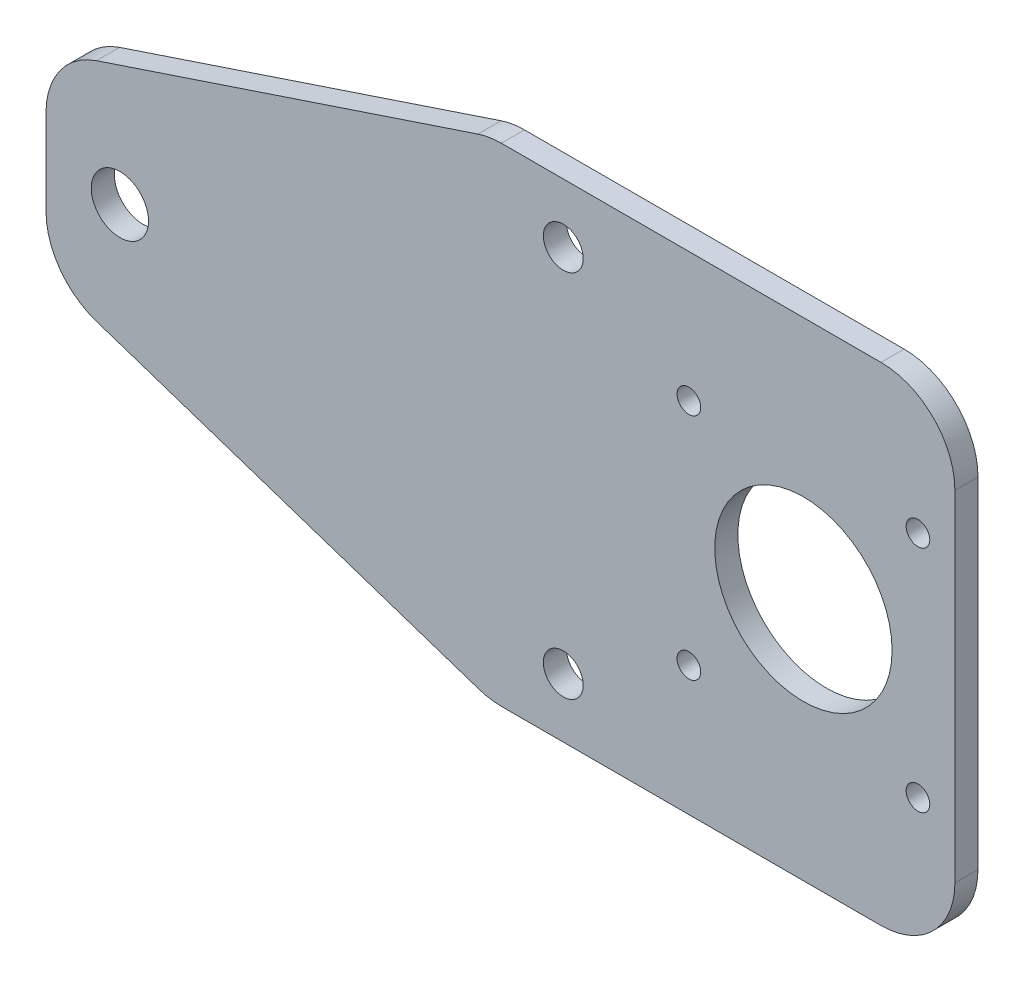
from build123d import *

# Parameters (mm, degrees)
MODEL_R             = 2.7
MODEL_R_2           = 3.875
MODEL_R_3           = 12
MODEL_R_4           = 1.6
BOSS_EXTRUDE1_DEPTH = 3.125
FILLET1_R           = 10


with BuildPart() as part:
    # Model → Boss-Extrude1 (new body)
    with BuildSketch(Plane.XY):
        Polygon((-0.063524835, 46), (-0.063524835, 20), (60, 0), (122.936475165, 0), (122.936475165, 66), (59.936475165, 66), align=None)
        with Locations((69.936475165, 8)):
            Circle(MODEL_R, mode=Mode.SUBTRACT)
        with Locations((9.936475165, 33)):
            Circle(MODEL_R_2, mode=Mode.SUBTRACT)
        with Locations((69.936475165, 58)):
            Circle(MODEL_R, mode=Mode.SUBTRACT)
        with Locations((102.436475165, 33)):
            Circle(MODEL_R_3, mode=Mode.SUBTRACT)
        with Locations((86.936475165, 48.5)):
            Circle(MODEL_R_4, mode=Mode.SUBTRACT)
        with Locations((117.936475165, 48.5)):
            Circle(MODEL_R_4, mode=Mode.SUBTRACT)
        with Locations((86.936475165, 17.5)):
            Circle(MODEL_R_4, mode=Mode.SUBTRACT)
        with Locations((117.936475165, 17.5)):
            Circle(MODEL_R_4, mode=Mode.SUBTRACT)
    extrude(amount=BOSS_EXTRUDE1_DEPTH)

    # Fillet1
    fillet1_edges = [part.edges().sort_by_distance(p)[0] for p in [
        (59.936475165, 66, 1.5625),
        (122.936475165, 66, 1.5625),
        (122.936475165, 0, 1.5625),
        (60, 0, 1.5625),
        (-0.063524835, 20, 1.5625),
        (-0.063524835, 46, 1.5625),
    ]]
    fillet(fillet1_edges, radius=FILLET1_R)


solid = part.part
